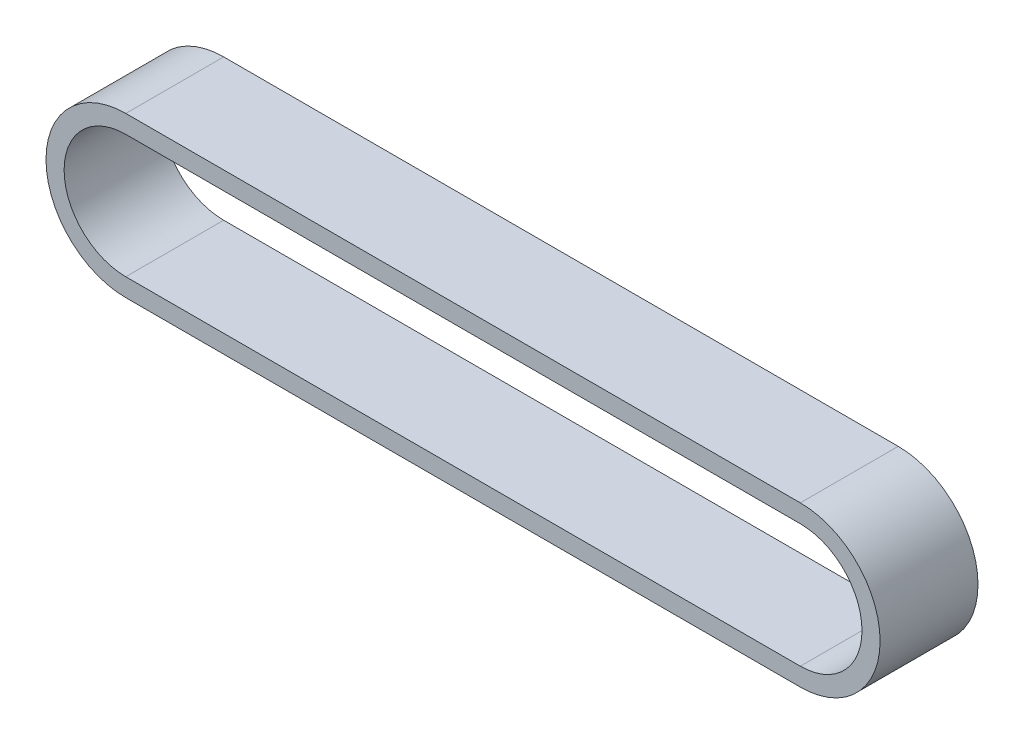
from build123d import *

# Parameters (mm, degrees)
BOSS_EXTRUDE1_DEPTH = 25.4


with BuildPart() as part:
    # Sketch1 → Boss-Extrude1 (new body)
    with BuildSketch(Plane.XY):
        with BuildLine():
            Line((87.5, -20.7), (-87.5, -20.7))
            ThreePointArc((-87.5, -20.7), (-108.2, 0), (-87.5, 20.7))
            Line((-87.5, 20.7), (87.5, 20.7))
            ThreePointArc((87.5, 20.7), (108.2, 0), (87.5, -20.7))
        make_face()
        with BuildLine():
            Line((87.5, -16), (-87.5, -16))
            ThreePointArc((-87.5, -16), (-103.5, 0), (-87.5, 16))
            Line((-87.5, 16), (87.5, 16))
            ThreePointArc((87.5, 16), (103.5, 0), (87.5, -16))
        make_face(mode=Mode.SUBTRACT)
    extrude(amount=BOSS_EXTRUDE1_DEPTH)


solid = part.part
